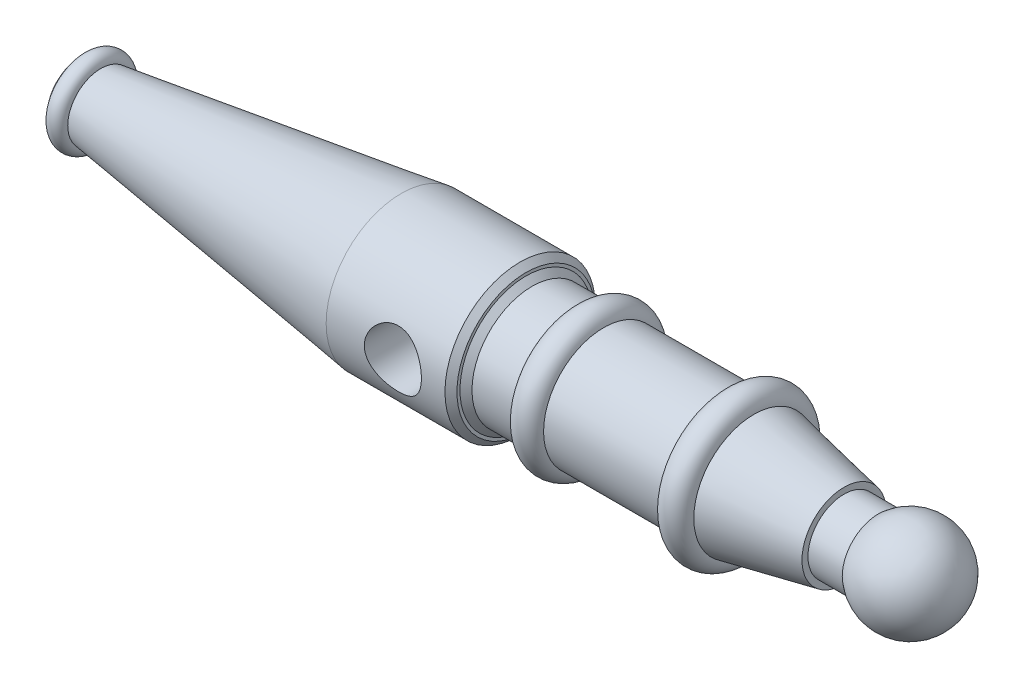
from build123d import *

# Parameters (mm, degrees)
CHAMFER1_SIZE           = 10
SKETCH3_R               = 47.5
CUT_EXTRUDE2_DEPTH      = 126.0000001
CUT_EXTRUDE2_DEPTH_BACK = 126.0000001
SKETCH4_R               = 47.5
CUT_EXTRUDE3_DEPTH      = 16
CUT_EXTRUDE3_TAPER      = 45
SKETCH5_R               = 32
CUT_EXTRUDE4_DEPTH      = 375
SKETCH6_R               = 32
CUT_EXTRUDE5_DEPTH      = 9
CUT_EXTRUDE5_TAPER      = 60
SKETCH7_R               = 16
CUT_EXTRUDE6_DEPTH      = 93
SKETCH8_R               = 16
CUT_EXTRUDE7_DEPTH      = 9
CUT_EXTRUDE7_TAPER      = 60


with BuildPart() as part:
    # Sketch1 → Revolve12 (revolve)
    with BuildSketch(Plane.XY):
        with BuildLine():
            ThreePointArc((4, 55), (19, 70), (34, 55))
            Line((34, 55), (534, 125))
            Line((534, 125), (741.714667413, 125))
            Line((741.714667413, 125), (741.714667413, 100))
            Line((741.714667413, 100), (821.714667413, 100))
            ThreePointArc((821.714667413, 100), (846.281702677, 120.36742206), (870.84873794, 100))
            Line((870.84873794, 100), (1070.84873794, 100))
            ThreePointArc((1070.84873794, 100), (1095.84873794, 125), (1120.84873794, 100))
            Line((1120.84873794, 100), (1270.84873794, 70))
            Line((1270.84873794, 70), (1270.84873794, 60))
            Line((1270.84873794, 60), (1327.84873794, 60))
            ThreePointArc((1327.84873794, 60), (1413.678790383, 72.915026221), (1460.763764161, 0))
            Line((1460.763764161, 0), (0, 0))
            Line((0, 0), (0, 55))
            Line((0, 55), (4, 55))
        make_face()
    revolve(axis=Axis((0, 0, 0), (1, 0, 0)))

    # Chamfer1
    chamfer1_edges = [part.edges().sort_by_distance(p)[0] for p in [
        (741.714667413, -125, 0),
        (741.714667413, -100, 0),
    ]]
    chamfer(chamfer1_edges, length=CHAMFER1_SIZE)

    # Sketch3 → Cut-Extrude2 (cut, two sides)
    with BuildSketch(Plane.XY) as cut_extrude2_sk:
        with Locations((645, 0)):
            Circle(SKETCH3_R)
    extrude(amount=CUT_EXTRUDE2_DEPTH, mode=Mode.SUBTRACT)
    extrude(cut_extrude2_sk.sketch, amount=-CUT_EXTRUDE2_DEPTH_BACK, mode=Mode.SUBTRACT)

    # Sketch4 → Cut-Extrude3 (cut)
    with BuildSketch(Plane.ZY):
        Circle(SKETCH4_R)
    extrude(amount=-CUT_EXTRUDE3_DEPTH, taper=CUT_EXTRUDE3_TAPER, mode=Mode.SUBTRACT)

    # Sketch5 → Cut-Extrude4 (cut)
    with BuildSketch(Plane.ZY.offset(-16)):
        Circle(SKETCH5_R)
    extrude(amount=-CUT_EXTRUDE4_DEPTH, mode=Mode.SUBTRACT)

    # Sketch6 → Cut-Extrude5 (cut)
    with BuildSketch(Plane.ZY.offset(-391)):
        Circle(SKETCH6_R)
    extrude(amount=-CUT_EXTRUDE5_DEPTH, taper=CUT_EXTRUDE5_TAPER, mode=Mode.SUBTRACT)

    # Sketch7 → Cut-Extrude6 (cut)
    with BuildSketch(Plane.ZY.offset(-400)):
        Circle(SKETCH7_R)
    extrude(amount=-CUT_EXTRUDE6_DEPTH, mode=Mode.SUBTRACT)

    # Sketch8 → Cut-Extrude7 (cut)
    with BuildSketch(Plane.ZY.offset(-493)):
        Circle(SKETCH8_R)
    extrude(amount=-CUT_EXTRUDE7_DEPTH, taper=CUT_EXTRUDE7_TAPER, mode=Mode.SUBTRACT)


solid = part.part
